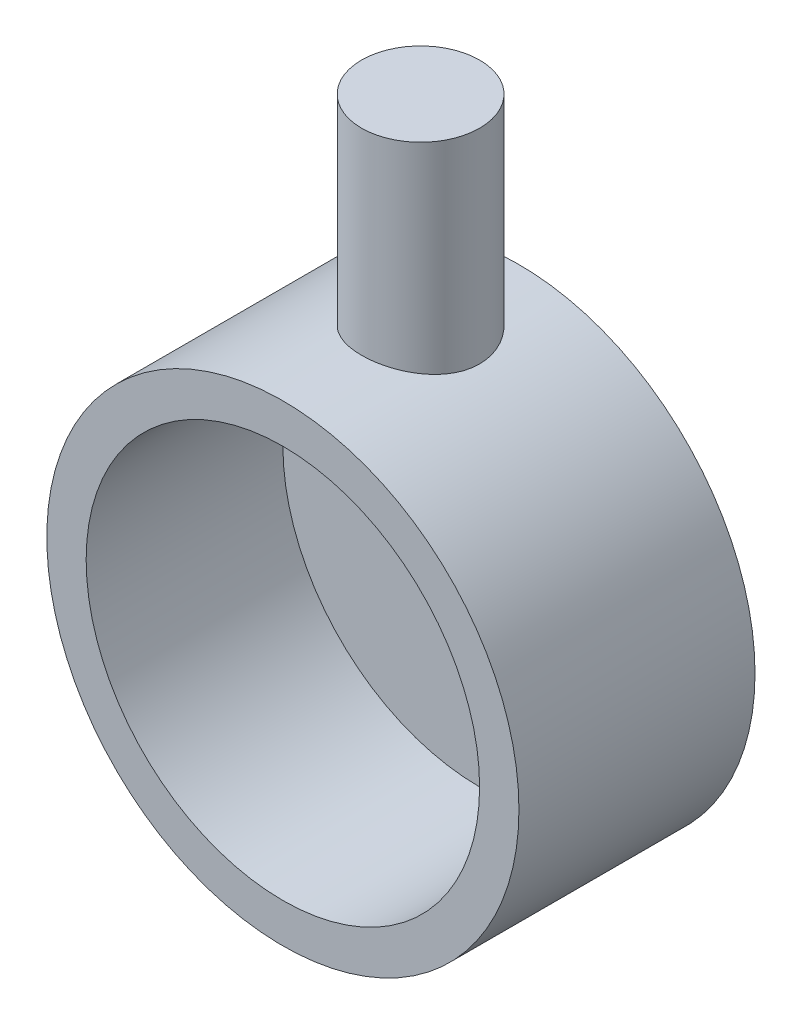
from build123d import *

# Parameters (mm, degrees)
SKETCH_1_R          = 30
EXTRUDE_1_DEPTH     = 30
SKETCH_3_R          = 7.5
EXTRUDE_2_DEPTH     = 55
SKETCH_4_R          = 25
CUT_EXTRUDE_2_DEPTH = 25


with BuildPart() as part:
    # 草图1 → 凸台-拉伸1 (new body)
    with BuildSketch(Plane.XY):
        Circle(SKETCH_1_R)
    extrude(amount=EXTRUDE_1_DEPTH)

    # 草图3 → 凸台-拉伸2 (add)
    with BuildSketch(Plane(origin=(0, 0, 0), x_dir=(1, 0, 0), z_dir=(0, 1, 0))):
        with Locations((0, -12.5)):
            Circle(SKETCH_3_R)
    extrude(amount=EXTRUDE_2_DEPTH)

    # 草图4 → 切除-拉伸2 (cut)
    with BuildSketch(Plane.XY.offset(30)):
        Circle(SKETCH_4_R)
    extrude(amount=-CUT_EXTRUDE_2_DEPTH, mode=Mode.SUBTRACT)


solid = part.part
